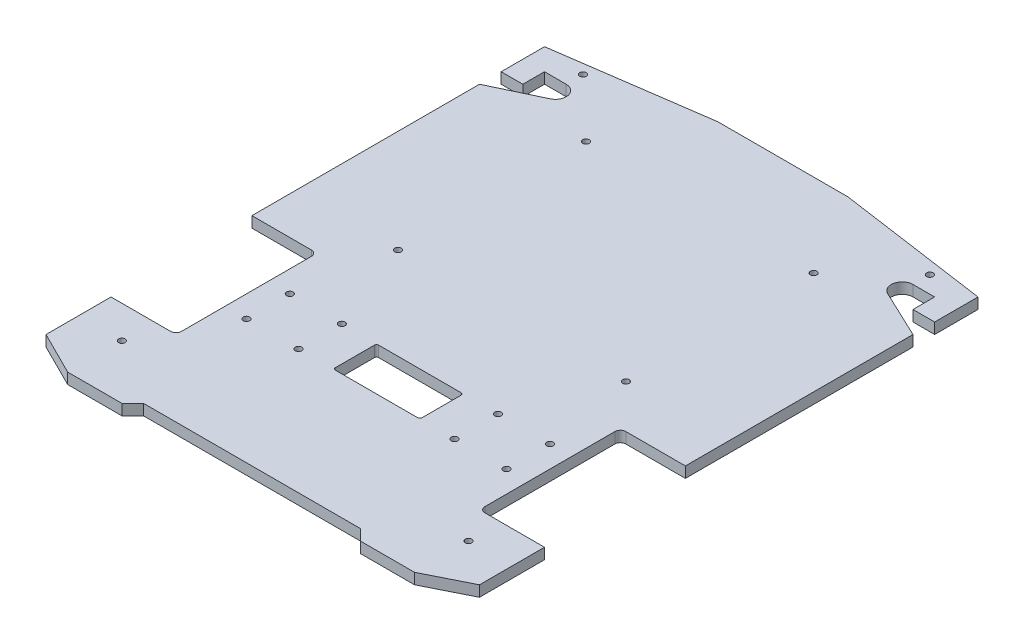
from build123d import *

# Parameters (mm, degrees)
SKETCH_1_W           = 200
SKETCH_1_H           = 250
EXTRUDE_1_DEPTH      = 5
CUT_EXTRUDE_1_DEPTH  = 35
CUT_EXTRUDE_2_DEPTH  = 35
CUT_EXTRUDE_5_DEPTH  = 30
CUT_EXTRUDE_6_DEPTH  = 10
SKETCH_9_R           = 1.5
CUT_EXTRUDE_8_DEPTH  = 10
SKETCH_10_R          = 1.5
CUT_EXTRUDE_9_DEPTH  = 10
CUT_EXTRUDE_12_DEPTH = 10
SKETCH_15_R          = 1.5
CUT_EXTRUDE_13_DEPTH = 10
SKETCH_16_R          = 1.5
CUT_EXTRUDE_14_DEPTH = 10
CUT_EXTRUDE_15_DEPTH = 10


with BuildPart() as part:
    # 草图1 → 凸台-拉伸1 (new body)
    with BuildSketch(Plane(origin=(0, 0, 0), x_dir=(1, 0, 0), z_dir=(0, 1, 0))):
        Rectangle(SKETCH_1_W, SKETCH_1_H)
    extrude(amount=EXTRUDE_1_DEPTH)

    # 草图2 → 切除-拉伸1 (cut)
    with BuildSketch(Plane(origin=(0, 5, 0), x_dir=(1, 0, 0), z_dir=(0, 1, 0))):
        Polygon((-100, -115), (-80, -125), (-100, -125), align=None)
    cut_extrude_1 = extrude(amount=-CUT_EXTRUDE_1_DEPTH, mode=Mode.SUBTRACT)

    # 镜向1: 切除-拉伸1 across plane
    add(cut_extrude_1.mirror(Plane(origin=(0, 0, 0), x_dir=(0, 0, 1), z_dir=(1, 0, 0))), mode=Mode.SUBTRACT)

    # 草图3 → 切除-拉伸2 (cut)
    with BuildSketch(Plane(origin=(0, 5, 0), x_dir=(1, 0, 0), z_dir=(0, 1, 0))):
        Polygon((-55, -125), (-50, -120), (0, -120), (0, -125), align=None)
    cut_extrude_2 = extrude(amount=-CUT_EXTRUDE_2_DEPTH, mode=Mode.SUBTRACT)

    # 镜向2: 切除-拉伸2 across plane
    add(cut_extrude_2.mirror(Plane(origin=(0, 0, 0), x_dir=(0, 0, 1), z_dir=(1, 0, 0))), mode=Mode.SUBTRACT)

    # 草图5 → 切除-拉伸5 (cut)
    with BuildSketch(Plane(origin=(0, 0, 0), x_dir=(1, 0, 0), z_dir=(0, 1, 0))):
        Polygon((-30, 125), (-100, 115), (-100, 125), align=None)
    cut_extrude_5 = extrude(amount=CUT_EXTRUDE_5_DEPTH, mode=Mode.SUBTRACT)

    # 镜向3: 切除-拉伸5 across plane
    add(cut_extrude_5.mirror(Plane(origin=(0, 0, 0), x_dir=(0, 0, 1), z_dir=(1, 0, 0))), mode=Mode.SUBTRACT)

    # 草图6 → 切除-拉伸6 (cut)
    with BuildSketch(Plane(origin=(0, 5, 0), x_dir=(1, 0, 0), z_dir=(0, 1, 0))):
        with BuildLine():
            Line((-100, 95), (-90, 95))
            Line((-90, 95), (-90, 105))
            Line((-90, 105), (-80, 105))
            ThreePointArc((-80, 105), (-75.121684822, 101.096376317), (-77.860612309, 95.480816412))
            Line((-77.860612309, 95.480816412), (-100, 85))
            Line((-100, 85), (-100, 95))
        make_face()
    cut_extrude_6 = extrude(amount=-CUT_EXTRUDE_6_DEPTH, mode=Mode.SUBTRACT)

    # 镜向4: 切除-拉伸6 across plane
    add(cut_extrude_6.mirror(Plane(origin=(0, 0, 0), x_dir=(0, 0, 1), z_dir=(1, 0, 0))), mode=Mode.SUBTRACT)

    # 草图9 → 切除-拉伸8 (cut)
    with BuildSketch(Plane(origin=(0, 5, 0), x_dir=(1, 0, 0), z_dir=(0, 1, 0))):
        with Locations((-80, -100)):
            Circle(SKETCH_9_R)
        with Locations((80, -100)):
            Circle(SKETCH_9_R)
    extrude(amount=-CUT_EXTRUDE_8_DEPTH, mode=Mode.SUBTRACT)

    # 草图10 → 切除-拉伸9 (cut)
    with BuildSketch(Plane(origin=(0, 5, 0), x_dir=(1, 0, 0), z_dir=(0, 1, 0))):
        with Locations((-80, 112.806380134)):
            Circle(SKETCH_10_R)
        with Locations((80, 112.806380134)):
            Circle(SKETCH_10_R)
    extrude(amount=-CUT_EXTRUDE_9_DEPTH, mode=Mode.SUBTRACT)

    # 草图14 → 切除-拉伸12 (cut)
    with BuildSketch(Plane(origin=(0, 5, 0), x_dir=(1, 0, 0), z_dir=(0, 1, 0))):
        with BuildLine():
            Line((-100, -85), (-72.5, -85))
            ThreePointArc((-72.5, -85), (-70.732233047, -84.267766953), (-70, -82.5))
            Line((-70, -82.5), (-70, -22.5))
            ThreePointArc((-70, -22.5), (-70.732233047, -20.732233047), (-72.5, -20))
            Line((-72.5, -20), (-100, -20))
            Line((-100, -20), (-100, -85))
        make_face()
        with BuildLine():
            Line((100, -20), (100, -85))
            Line((100, -85), (72.5, -85))
            ThreePointArc((72.5, -85), (70.732233047, -84.267766953), (70, -82.5))
            Line((70, -82.5), (70, -22.5))
            ThreePointArc((70, -22.5), (70.732233047, -20.732233047), (72.5, -20))
            Line((72.5, -20), (100, -20))
        make_face()
    extrude(amount=-CUT_EXTRUDE_12_DEPTH, mode=Mode.SUBTRACT)

    # 草图15 → 切除-拉伸13 (cut)
    with BuildSketch(Plane(origin=(0, 5, 0), x_dir=(1, 0, 0), z_dir=(0, 1, 0))):
        with Locations((-52.53096351, 0)):
            Circle(SKETCH_15_R)
        with Locations((-52.53096351, 86.645023586)):
            Circle(SKETCH_15_R)
        with Locations((52.53096351, 0)):
            Circle(SKETCH_15_R)
        with Locations((52.53096351, 86.645023586)):
            Circle(SKETCH_15_R)
    extrude(amount=-CUT_EXTRUDE_13_DEPTH, mode=Mode.SUBTRACT)

    # 草图16 → 切除-拉伸14 (cut)
    with BuildSketch(Plane.XZ):
        with Locations((60, 62.5)):
            Circle(SKETCH_16_R)
        with Locations((60, 42.5)):
            Circle(SKETCH_16_R)
        with Locations((36, 42.5)):
            Circle(SKETCH_16_R)
        with Locations((36, 62.5)):
            Circle(SKETCH_16_R)
    cut_extrude_14 = extrude(amount=-CUT_EXTRUDE_14_DEPTH, mode=Mode.SUBTRACT)

    # 镜向5: 切除-拉伸14 across plane
    add(cut_extrude_14.mirror(Plane(origin=(0, 0, 0), x_dir=(0, 0, 1), z_dir=(1, 0, 0))), mode=Mode.SUBTRACT)

    # 草图18 → 切除-拉伸15 (cut)
    with BuildSketch(Plane(origin=(0, 5, 0), x_dir=(1, 0, 0), z_dir=(0, 1, 0))):
        with BuildLine():
            Line((-19, -62.5), (19, -62.5))
            ThreePointArc((19, -62.5), (19.707106781, -62.207106781), (20, -61.5))
            Line((20, -61.5), (20, -43.5))
            ThreePointArc((20, -43.5), (19.707106781, -42.792893219), (19, -42.5))
            Line((19, -42.5), (-19, -42.5))
            ThreePointArc((-19, -42.5), (-19.707106781, -42.792893219), (-20, -43.5))
            Line((-20, -43.5), (-20, -61.5))
            ThreePointArc((-20, -61.5), (-19.707106781, -62.207106781), (-19, -62.5))
        make_face()
    extrude(amount=-CUT_EXTRUDE_15_DEPTH, mode=Mode.SUBTRACT)


solid = part.part
